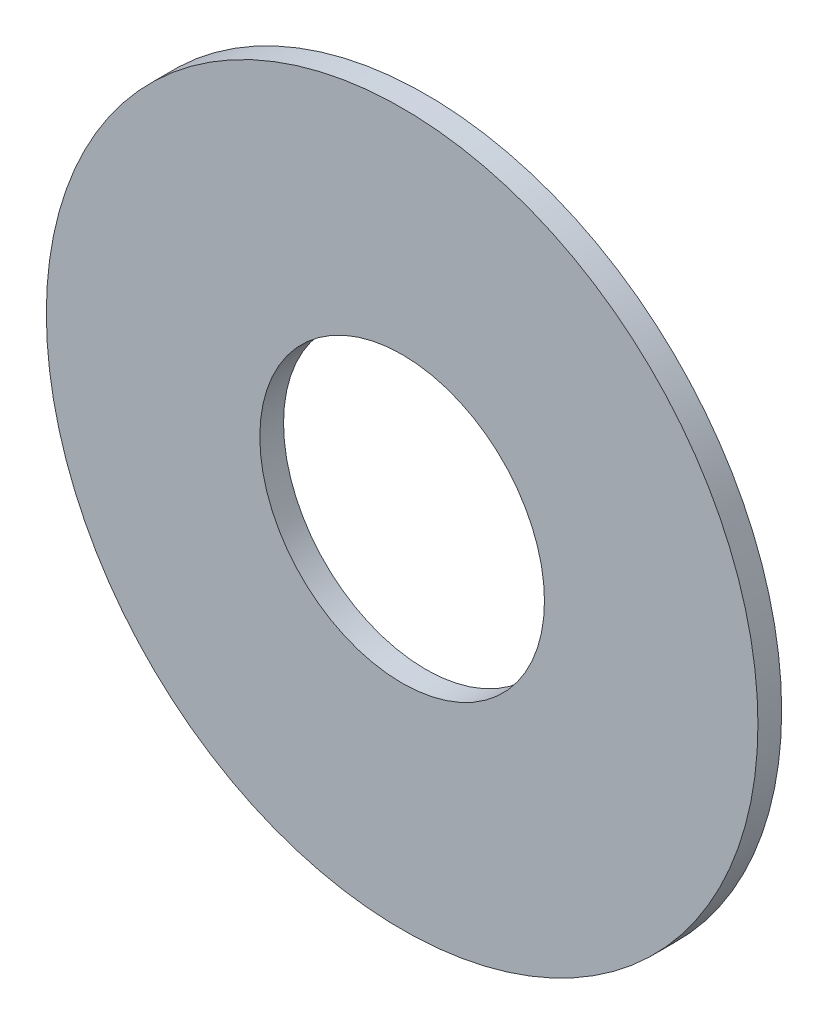
from build123d import *

# Parameters (mm, degrees)
SKETCH_1_R      = 15
SKETCH_1_R_2    = 6
EXTRUDE_1_DEPTH = 1


with BuildPart() as part:
    # Эскиз1 → Бобышка-Вытянуть1 (new body)
    with BuildSketch(Plane.XY):
        Circle(SKETCH_1_R)
        Circle(SKETCH_1_R_2, mode=Mode.SUBTRACT)
    extrude(amount=EXTRUDE_1_DEPTH)


solid = part.part
